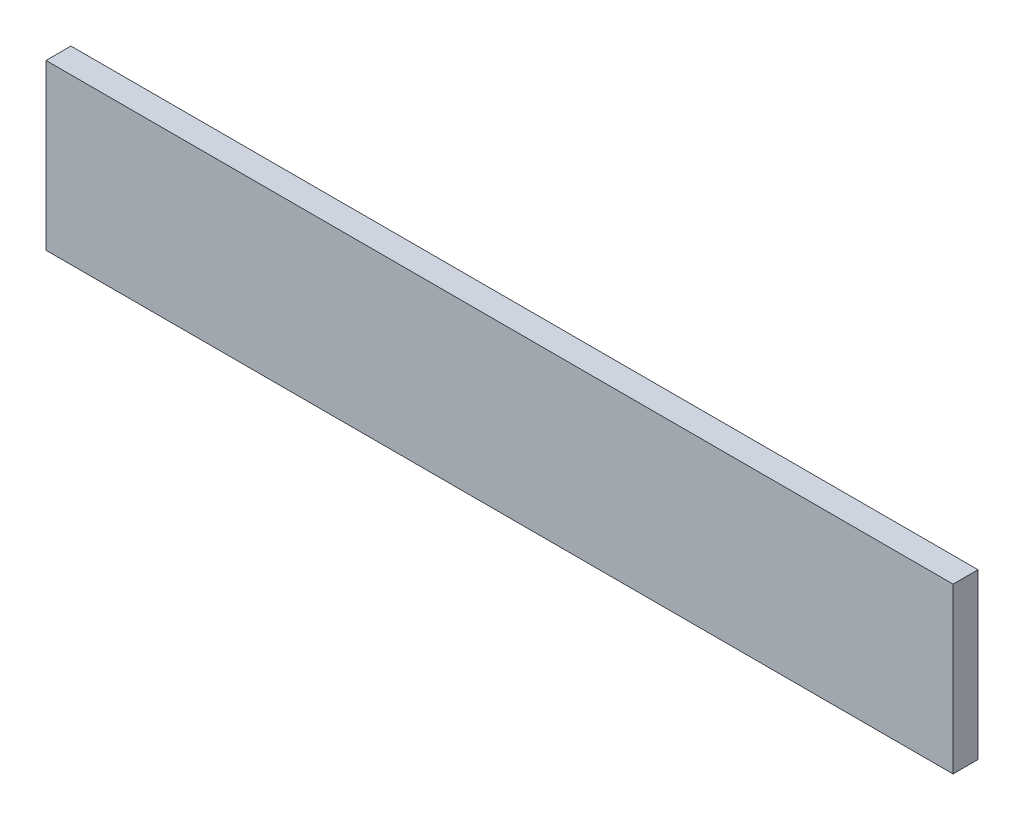
from build123d import *

# Parameters (mm, degrees)
SKETCH1_W           = 800
SKETCH1_H           = 145
BOSS_EXTRUDE1_DEPTH = 22


with BuildPart() as part:
    # Sketch1 → Boss-Extrude1 (new body)
    with BuildSketch(Plane.XY):
        Rectangle(SKETCH1_W, SKETCH1_H)
    extrude(amount=BOSS_EXTRUDE1_DEPTH)


solid = part.part
